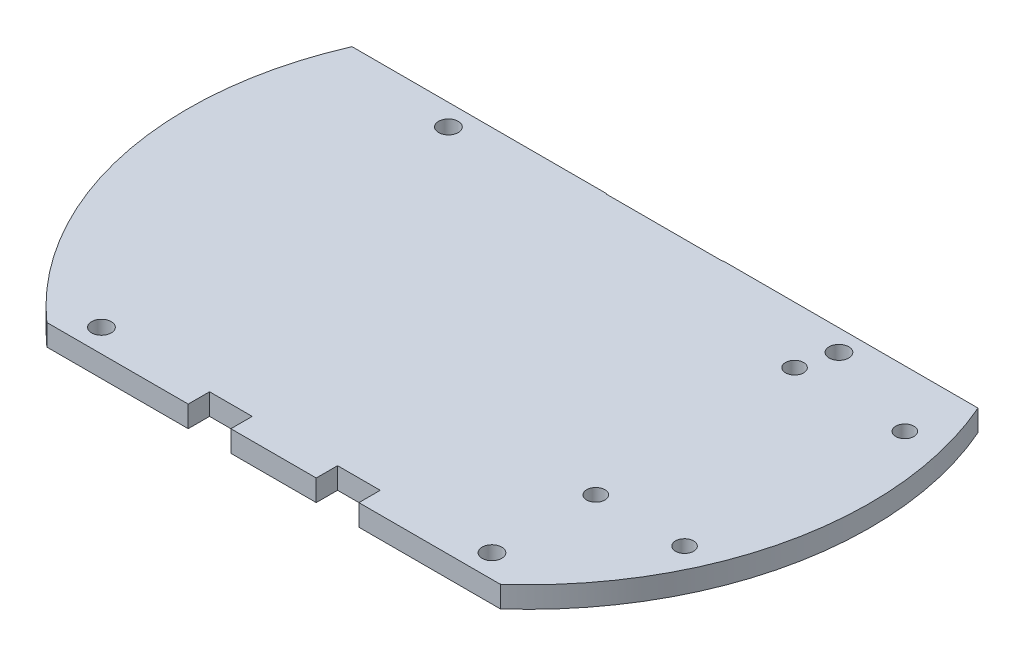
from build123d import *

# Parameters (mm, degrees)
SKETCH1_R           = 50.8
BOSS_EXTRUDE1_DEPTH = 3.175
SKETCH2_W           = 114.887790664
SKETCH2_H           = 17.737062418
CUT_EXTRUDE1_DEPTH  = 3.175
SKETCH6_R           = 1.4605
CUT_EXTRUDE2_DEPTH  = 3.175
SKETCH7_W           = 120.831003793
SKETCH7_H           = 28.526712532
CUT_EXTRUDE3_DEPTH  = 3.175
SKETCH8_W           = 6.35
SKETCH8_H           = 3.175
CUT_EXTRUDE4_DEPTH  = 3.175
SKETCH9_R           = 1.3462
CUT_EXTRUDE5_DEPTH  = 3.175


with BuildPart() as part:
    # Sketch1 → Boss-Extrude1 (new body)
    with BuildSketch(Plane(origin=(0, 0, 0), x_dir=(1, 0, 0), z_dir=(0, 1, 0))):
        Circle(SKETCH1_R)
    extrude(amount=BOSS_EXTRUDE1_DEPTH)

    # Sketch2 → Cut-Extrude1 (cut)
    with BuildSketch(Plane(origin=(0, 3.175, 0), x_dir=(1, 0, 0), z_dir=(0, 1, 0))):
        with BuildLine():
            Line((-53.141111112, 55.715142418), (61.746679552, 55.715142418))
            Line((61.746679552, 55.715142418), (61.746679552, 37.97808))
            Line((61.746679552, 37.97808), (17.466405486, 37.97808))
            add(Edge.make_bspline(
                [(17.466405486, 37.97808), (17.038082166, 26.714286782), (8.597103322, 20.19808)],
                knots=[0, 0, 0, 1, 1, 1], degree=2))
            Line((8.597103322, 20.19808), (-8.597103322, 20.19808))
            add(Edge.make_bspline(
                [(-17.466405486, 37.97808), (-17.038082166, 26.714286782), (-8.597103322, 20.19808)],
                knots=[0, 0, 0, 1, 1, 1], degree=2))
            Line((-17.466405486, 37.97808), (-53.141111112, 37.97808))
            Line((-53.141111112, 37.97808), (-53.141111112, 55.715142418))
        make_face()
        with Locations((4.30278422, -46.846611209)):
            Rectangle(SKETCH2_W, SKETCH2_H)
    extrude(amount=-CUT_EXTRUDE1_DEPTH, mode=Mode.SUBTRACT)

    # Sketch6 → Cut-Extrude2 (cut)
    with BuildSketch(Plane(origin=(0, 3.175, 0), x_dir=(1, 0, 0), z_dir=(0, 1, 0))):
        with Locations((-29.0576, 17.10182)):
            Circle(SKETCH6_R)
        with Locations((29.0576, 17.10182)):
            Circle(SKETCH6_R)
        with Locations((29.0576, -34.53638)):
            Circle(SKETCH6_R)
        with Locations((-29.0576, -34.53638)):
            Circle(SKETCH6_R)
    extrude(amount=-CUT_EXTRUDE2_DEPTH, mode=Mode.SUBTRACT)

    # Sketch7 → Cut-Extrude3 (cut)
    with BuildSketch(Plane.XZ):
        with Locations((-2.634885915, -34.53847722)):
            Rectangle(SKETCH7_W, SKETCH7_H)
    extrude(amount=-CUT_EXTRUDE3_DEPTH, mode=Mode.SUBTRACT)

    # Sketch8 → Cut-Extrude4 (cut)
    with BuildSketch(Plane.XZ):
        with Locations((-9.525, 36.39058)):
            Rectangle(SKETCH8_W, SKETCH8_H)
        with Locations((9.525, 36.39058)):
            Rectangle(SKETCH8_W, SKETCH8_H)
    extrude(amount=-CUT_EXTRUDE4_DEPTH, mode=Mode.SUBTRACT)

    # Sketch9 → Cut-Extrude5 (cut)
    with BuildSketch(Plane(origin=(0, 3.175, 0), x_dir=(1, 0, 0), z_dir=(0, 1, 0))):
        with Locations((27.725400673, 11.828091507)):
            Circle(SKETCH9_R)
        with Locations((44.133800673, 11.828091507)):
            Circle(SKETCH9_R)
        with Locations((42.533600673, -19.350408493)):
            Circle(SKETCH9_R)
        with Locations((29.325600673, -19.350408493)):
            Circle(SKETCH9_R)
    extrude(amount=-CUT_EXTRUDE5_DEPTH, mode=Mode.SUBTRACT)


solid = part.part
